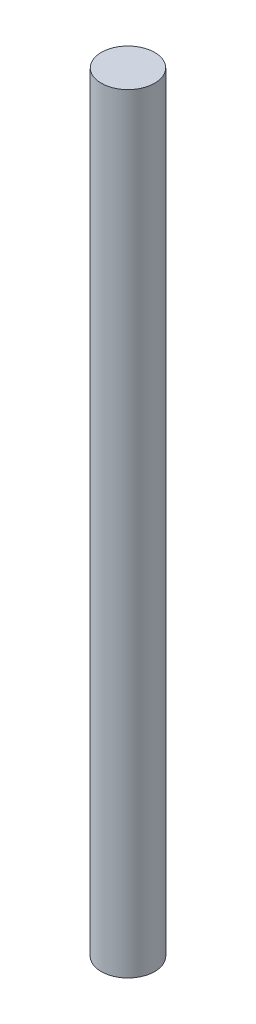
from build123d import *

# Parameters (mm, degrees)
SKETCH1_R           = 1.5875
BOSS_EXTRUDE1_DEPTH = 45.72


with BuildPart() as part:
    # Sketch1 → Boss-Extrude1 (new body)
    with BuildSketch(Plane(origin=(0, 0, 0), x_dir=(1, 0, 0), z_dir=(0, 1, 0))):
        Circle(SKETCH1_R)
    extrude(amount=BOSS_EXTRUDE1_DEPTH)


solid = part.part
